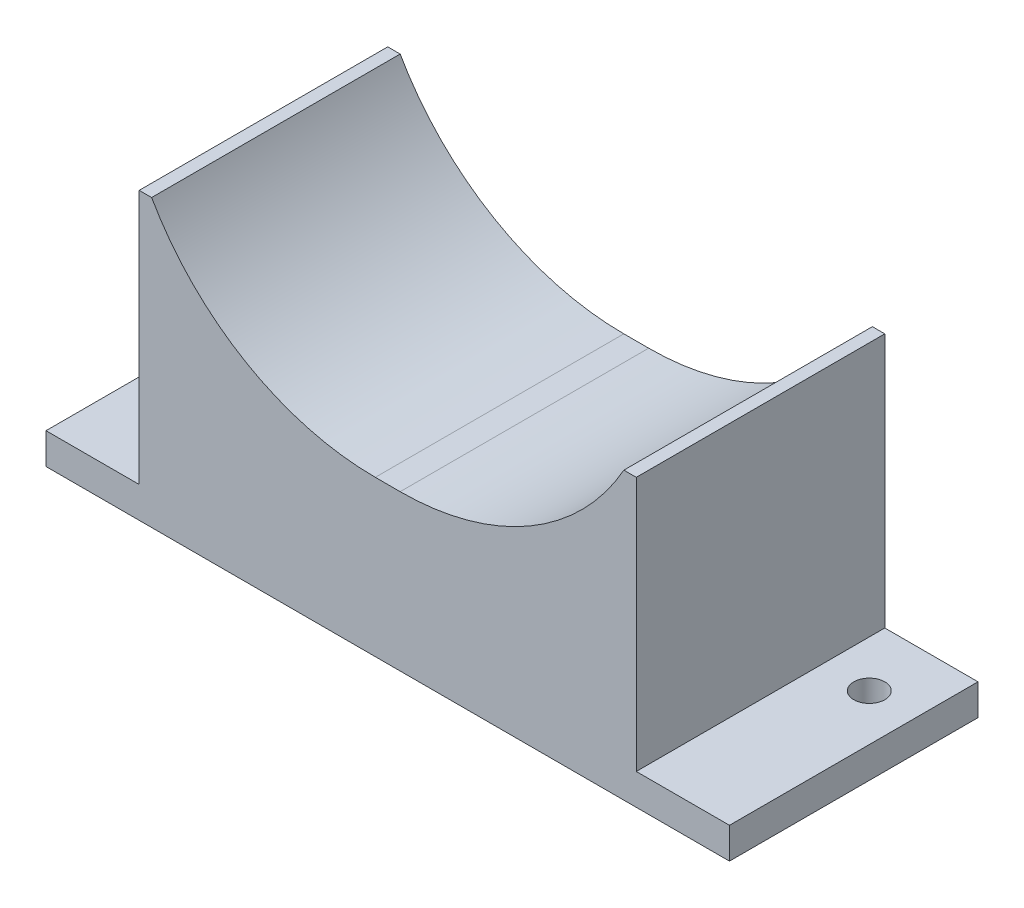
from build123d import *

# Parameters (mm, degrees)
BOSS_EXTRUDE1_DEPTH = 40
SKETCH3_R           = 2.5
CUT_EXTRUDE1_DEPTH  = 40


with BuildPart() as part:
    # Sketch1 → Boss-Extrude1 (new body)
    with BuildSketch(Plane.XY):
        with BuildLine():
            Line((55, 0), (-55, 0))
            Line((-55, 0), (-55, 5))
            Line((-55, 5), (-40, 5))
            Line((-40, 5), (-40, 46))
            Line((-40, 46), (-38, 46))
            ThreePointArc((-38, 46), (-22.838665984, 30.633715456), (-2, 25))
            Line((-2, 25), (2, 25))
            ThreePointArc((2, 25), (22.838665984, 30.633715456), (38, 46))
            Line((38, 46), (40, 46))
            Line((40, 46), (40, 5))
            Line((40, 5), (55, 5))
            Line((55, 5), (55, 0))
        make_face()
    extrude(amount=BOSS_EXTRUDE1_DEPTH)

    # Sketch3 → Cut-Extrude1 (cut)
    with BuildSketch(Plane(origin=(0, 5, 0), x_dir=(1, 0, 0), z_dir=(0, 1, 0))):
        with Locations((-47.5, -10)):
            Circle(SKETCH3_R)
        with Locations((47.5, -10)):
            Circle(SKETCH3_R)
    extrude(amount=-CUT_EXTRUDE1_DEPTH, mode=Mode.SUBTRACT)


solid = part.part
